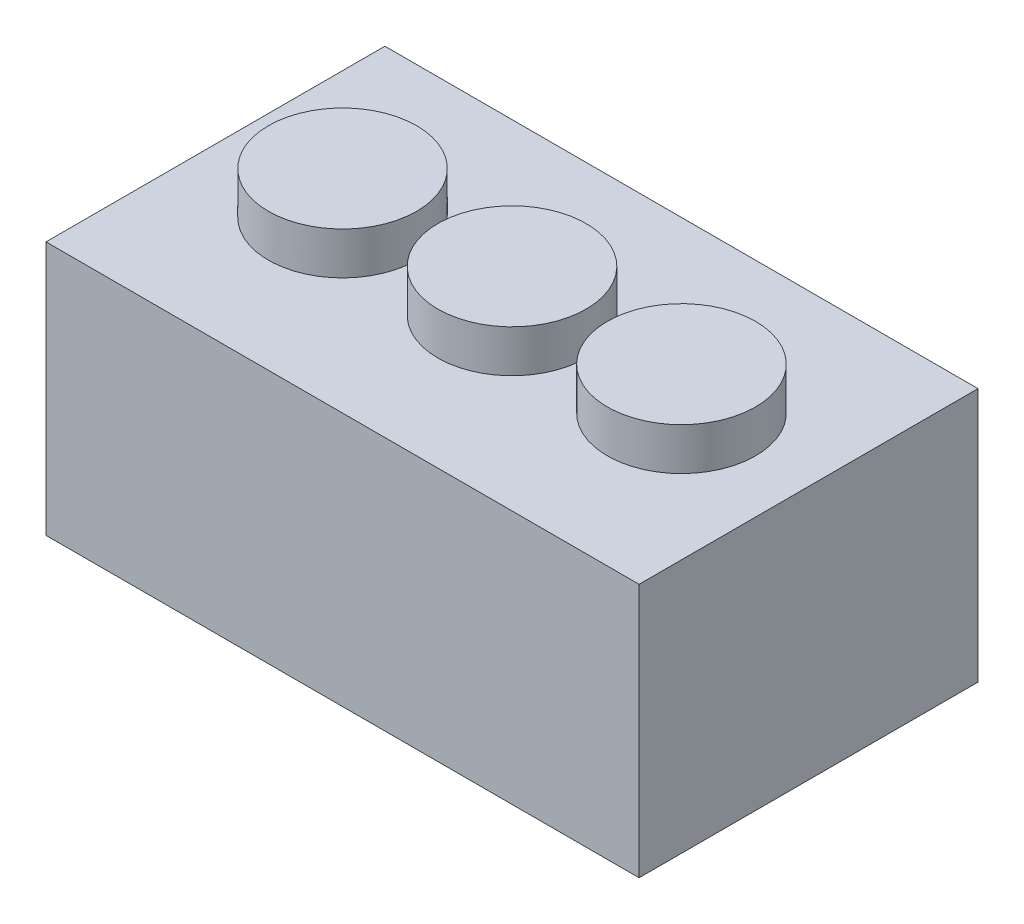
from build123d import *

# Parameters (mm, degrees)
CROQUIS1_W              = 140
CROQUIS1_H              = 80
SALIENTE_EXTRUIR1_DEPTH = 60
CROQUIS2_R              = 17.5
SALIENTE_EXTRUIR2_DEPTH = 10
VACIADO1_T              = -2
CROQUIS3_R              = 15.5
SALIENTE_EXTRUIR3_DEPTH = 58


with BuildPart() as part:
    # Croquis1 → Saliente-Extruir1 (new body)
    with BuildSketch(Plane(origin=(0, 0, 0), x_dir=(1, 0, 0), z_dir=(0, 1, 0))):
        Rectangle(CROQUIS1_W, CROQUIS1_H)
    extrude(amount=SALIENTE_EXTRUIR1_DEPTH)

    # Croquis2 → Saliente-Extruir2 (add)
    with BuildSketch(Plane(origin=(0, 60, 0), x_dir=(1, 0, 0), z_dir=(0, 1, 0))):
        with Locations(Location((0, 0, 0), (0, 0, 270))):  # turned: the seam where the file's is
            Circle(CROQUIS2_R)
        with Locations(Location((-40, 0, 0), (0, 0, 90))):  # turned: the seam where the file's is
            Circle(CROQUIS2_R)
        with Locations(Location((40, 0, 0), (0, 0, 90))):  # turned: the seam where the file's is
            Circle(CROQUIS2_R)
    extrude(amount=SALIENTE_EXTRUIR2_DEPTH)

    # Vaciado1
    vaciado1_openings = [part.faces().sort_by_distance(p)[0] for p in [
        (0, 0, 0),
    ]]
    offset(amount=VACIADO1_T, openings=vaciado1_openings, kind=Kind.INTERSECTION)

    # Croquis3 → Saliente-Extruir3 (add)
    with BuildSketch(Plane.XZ.offset(-58)):
        with BuildLine():
            Line((-68, -2), (-19.397164741, -2))
            ThreePointArc((-19.397164741, -2), (0, -19.5), (19.397164741, -2))
            Line((19.397164741, -2), (68, -2))
            Line((68, -2), (68, 2))
            Line((68, 2), (19.397164741, 2))
            ThreePointArc((19.397164741, 2), (0, 19.5), (-19.397164741, 2))
            Line((-19.397164741, 2), (-68, 2))
            Line((-68, 2), (-68, -2))
        make_face()
        with Locations(Location((0, 0, 0), (0, 0, 270))):  # turned: the seam where the file's is
            Circle(CROQUIS3_R, mode=Mode.SUBTRACT)
    extrude(amount=SALIENTE_EXTRUIR3_DEPTH)


solid = part.part
